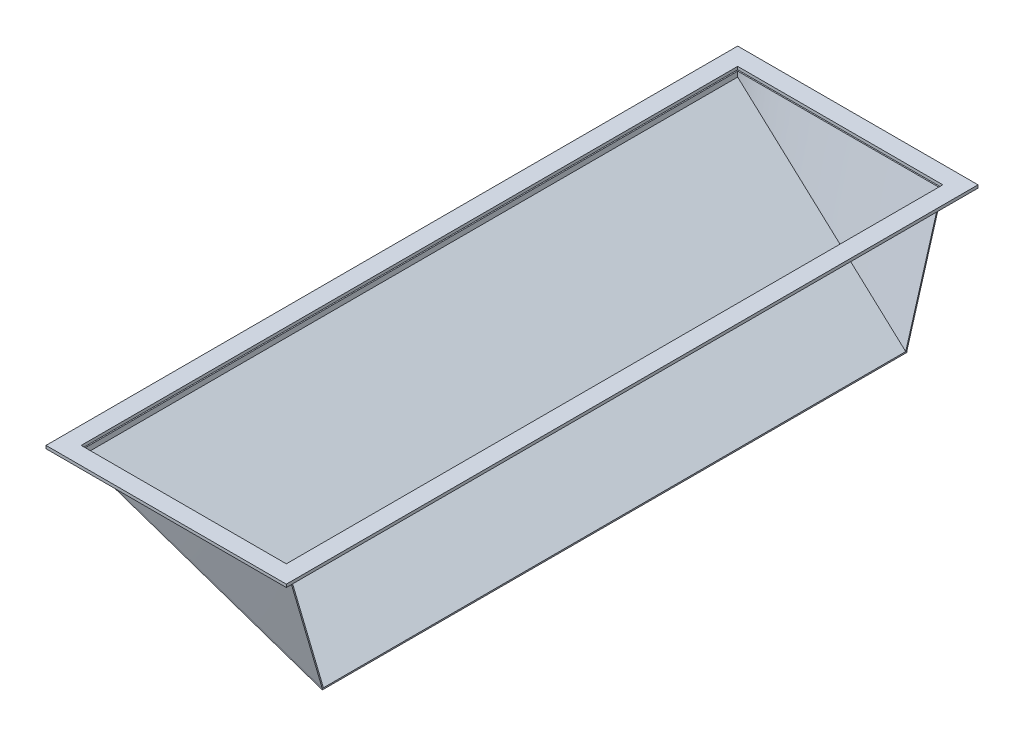
from build123d import *

# Parameters (mm, degrees)
DODANIE_WYCI_GNI_CIE1_DEPTH = 1120
SZKIC3_W                    = 410
SZKIC3_H                    = 1180
SZKIC3_W_2                  = 350
SZKIC3_H_2                  = 1120
DODANIE_WYCI_GNI_CIE2_DEPTH = 5
SKORUPA3_T                  = -2
WYTNIJ_WYCI_GNI_CIE1_DEPTH  = 90
SZKIC6_W                    = 348
SZKIC6_H                    = 2


with BuildPart() as part:
    # Szkic1 → Dodanie-wyciągnięcie1 (new body)
    with BuildSketch(Plane.XY):
        Polygon((0, 0), (350, 0), (350, -212.072594216), (0, -10), align=None)
    extrude(amount=DODANIE_WYCI_GNI_CIE1_DEPTH)

    # Skorupa3
    skorupa3_openings = [part.faces().sort_by_distance(p)[0] for p in [
        (228.07979599, -70.840965806, 1120),
        (228.07979599, -70.840965806, 0),
        (175, 0, 560),
        (350, -106.036297108, 560),
    ]]
    offset(amount=SKORUPA3_T, openings=skorupa3_openings, kind=Kind.INTERSECTION)

    # Szkic5 → Wytnij-wyciągnięcie1 (cut)
    with BuildSketch(Plane(origin=(-3.330127019, -5.767949192, 0), x_dir=(0.866025404, -0.5, 0), z_dir=(0.5, 0.866025404, 0))):
        Polygon((6.154700538, 0), (611.603832343, -92.327977863), (616.29746701, 26.332973574), (500.046687134, 176.768653302), align=None)
        Polygon((6.154700538, -1120), (574.381771599, -1033.348201059), (567.57139083, -1205.52313986), (177.827516191, -1478.396489856), align=None)
    extrude(amount=-WYTNIJ_WYCI_GNI_CIE1_DEPTH, mode=Mode.SUBTRACT)


with BuildPart() as body_2:
    # Szkic3 → Dodanie-wyciągnięcie2 (new body)
    with BuildSketch(Plane(origin=(0, 0, 0), x_dir=(1, 0, 0), z_dir=(0, 1, 0))):
        with Locations((175, -560)):
            Rectangle(SZKIC3_W, SZKIC3_H)
        with Locations((175, -560)):
            Rectangle(SZKIC3_W_2, SZKIC3_H_2, mode=Mode.SUBTRACT)
    extrude(amount=DODANIE_WYCI_GNI_CIE2_DEPTH)


with BuildPart() as body_3:
    # Szkic7 → Wyciągnięcie po profilach2 section 0
    with BuildSketch(Plane(origin=(-3.330127019, -5.767949192, 0), x_dir=(0.866025404, -0.5, 0), z_dir=(0.5, 0.866025404, 0))):
        Polygon((6.154700538, -1120), (407.990487894, -1058.722043305), (407.990487894, -1056.698904856), (6.154700538, -1118), align=None)
    # Szkic6 → Wyciągnięcie po profilach2 section 1
    with BuildSketch(Plane.XZ):
        with Locations((176, 1119)):
            Rectangle(SZKIC6_W, SZKIC6_H)
    loft()


with BuildPart() as body_4:
    # Lustro1: mirrored copy
    add(body_3.part.mirror(Plane(origin=(0, 0, 560), x_dir=(1, 0, 0), z_dir=(0, 0, -1))))


solid = Compound([part.part, body_2.part, body_3.part, body_4.part])
